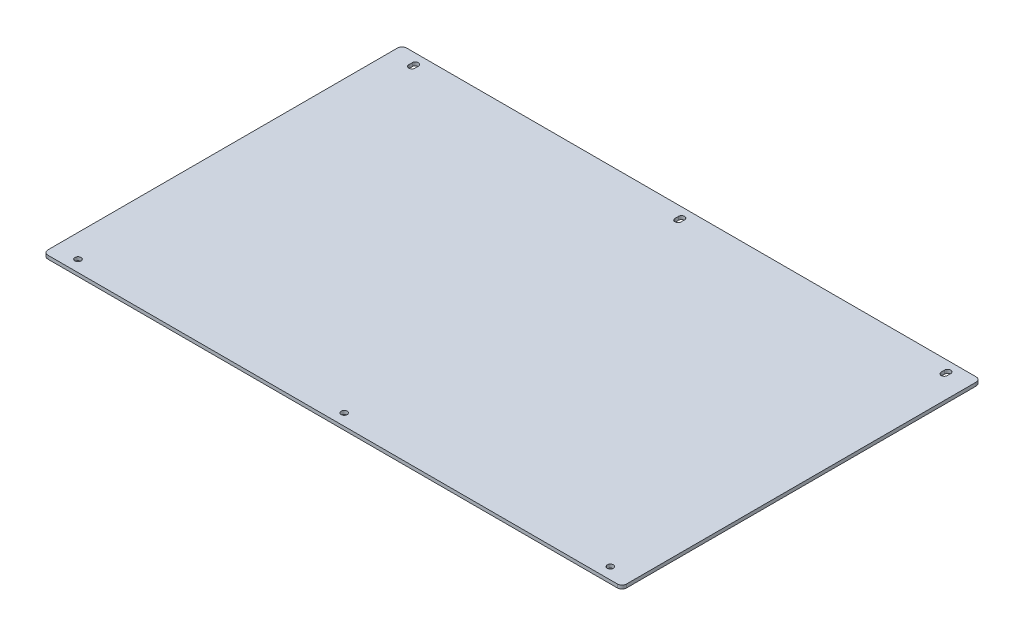
from build123d import *

# Parameters (mm, degrees)
SKETCH1_W                  = 500
SKETCH1_H                  = 310
BOSS_EXTRUDE1_DEPTH        = 3
FILLET1_R                  = 4
F_5_3_5_3_DIAMETER_HOLE1_D = 5.3
CUT_EXTRUDE2_DEPTH         = 4


with BuildPart() as part:
    # Sketch1 → Boss-Extrude1 (new body)
    with BuildSketch(Plane(origin=(0, 0, 0), x_dir=(1, 0, 0), z_dir=(0, 1, 0))):
        Rectangle(SKETCH1_W, SKETCH1_H)
    extrude(amount=BOSS_EXTRUDE1_DEPTH)

    # Fillet1
    fillet1_edges = [part.edges().sort_by_distance(p)[0] for p in [
        (250, 1.5, 155),
        (-250, 1.5, 155),
        (-250, 1.5, -155),
        (250, 1.5, -155),
    ]]
    fillet(fillet1_edges, radius=FILLET1_R)

    # Ø5.3 (5.3) Diameter Hole1 (through all)
    with Locations(Plane(origin=(0, 3, 0), x_dir=(1, 0, 0), z_dir=(0, 1, 0))):
        with Locations((230, 145), (-230, -145), (-230, 145), (230, -145), (0, 145), (0, -145)):
            Hole(F_5_3_5_3_DIAMETER_HOLE1_D / 2)

    # Sketch7 → Cut-Extrude2 (cut, through all)
    with BuildSketch(Plane(origin=(0, 3, 0), x_dir=(1, 0, 0), z_dir=(0, 1, 0))):
        with BuildLine():
            Line((-232.65, 143.5), (-232.65, 146.5))
            ThreePointArc((-232.65, 146.5), (-230, 149.15), (-227.35, 146.5))
            Line((-227.35, 146.5), (-227.35, 143.5))
            ThreePointArc((-227.35, 143.5), (-230, 140.85), (-232.65, 143.5))
        make_face()
        with BuildLine():
            Line((-2.65, 143.5), (-2.65, 146.5))
            ThreePointArc((-2.65, 146.5), (0, 149.15), (2.65, 146.5))
            Line((2.65, 146.5), (2.65, 143.5))
            ThreePointArc((2.65, 143.5), (0, 140.85), (-2.65, 143.5))
        make_face()
        with BuildLine():
            Line((227.35, 143.5), (227.35, 146.5))
            ThreePointArc((227.35, 146.5), (230, 149.15), (232.65, 146.5))
            Line((232.65, 146.5), (232.65, 143.5))
            ThreePointArc((232.65, 143.5), (230, 140.85), (227.35, 143.5))
        make_face()
    extrude(amount=-CUT_EXTRUDE2_DEPTH, mode=Mode.SUBTRACT)


solid = part.part
